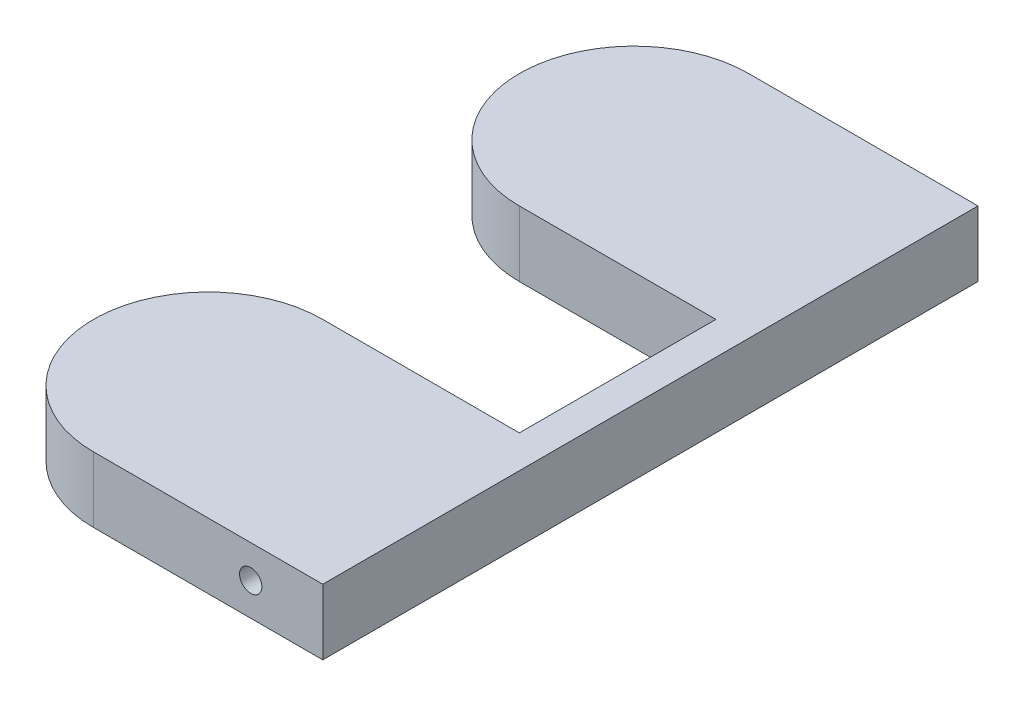
from build123d import *

# Parameters (mm, degrees)
BOSS_EXTRUDE1_DEPTH = 10
SKETCH2_R           = 1.705
CUT_EXTRUDE1_DEPTH  = 15
SKETCH3_W           = 7.3
SKETCH3_H           = 8.65
CUT_EXTRUDE2_DEPTH  = 8
SKETCH4_R           = 1.705
CUT_EXTRUDE3_DEPTH  = 15
SKETCH5_W           = 7.3
SKETCH5_H           = 8.65
CUT_EXTRUDE4_DEPTH  = 8


with BuildPart() as part:
    # Sketch1 → Boss-Extrude1 (new body)
    with BuildSketch(Plane(origin=(0, 0, 0), x_dir=(1, 0, 0), z_dir=(0, 1, 0))):
        with BuildLine():
            Line((5, 50), (5, -50))
            Line((5, -50), (-30, -50))
            ThreePointArc((-30, -50), (-47.5, -32.5), (-30, -15))
            Line((-30, -15), (0, -15))
            Line((0, -15), (0, 15))
            Line((0, 15), (-30, 15))
            ThreePointArc((-30, 15), (-47.5, 32.5), (-30, 50))
            Line((-30, 50), (5, 50))
        make_face()
    extrude(amount=BOSS_EXTRUDE1_DEPTH)

    # Sketch2 → Cut-Extrude1 (cut)
    with BuildSketch(Plane.XY.offset(50)):
        with Locations((-6, 5)):
            Circle(SKETCH2_R)
    extrude(amount=-CUT_EXTRUDE1_DEPTH, mode=Mode.SUBTRACT)

    # Sketch3 → Cut-Extrude2 (cut)
    with BuildSketch(Plane.XY.offset(35)):
        with Locations((-6, 4.325)):
            Rectangle(SKETCH3_W, SKETCH3_H)
    extrude(amount=CUT_EXTRUDE2_DEPTH, mode=Mode.SUBTRACT)

    # Sketch4 → Cut-Extrude3 (cut)
    with BuildSketch(Plane(origin=(0, 0, -50), x_dir=(-1, 0, 0), z_dir=(0, 0, -1))):
        with Locations((6, 5)):
            Circle(SKETCH4_R)
    extrude(amount=-CUT_EXTRUDE3_DEPTH, mode=Mode.SUBTRACT)

    # Sketch5 → Cut-Extrude4 (cut)
    with BuildSketch(Plane(origin=(0, 0, -35), x_dir=(-1, 0, 0), z_dir=(0, 0, -1))):
        with Locations((6, 4.325)):
            Rectangle(SKETCH5_W, SKETCH5_H)
    extrude(amount=CUT_EXTRUDE4_DEPTH, mode=Mode.SUBTRACT)


solid = part.part
